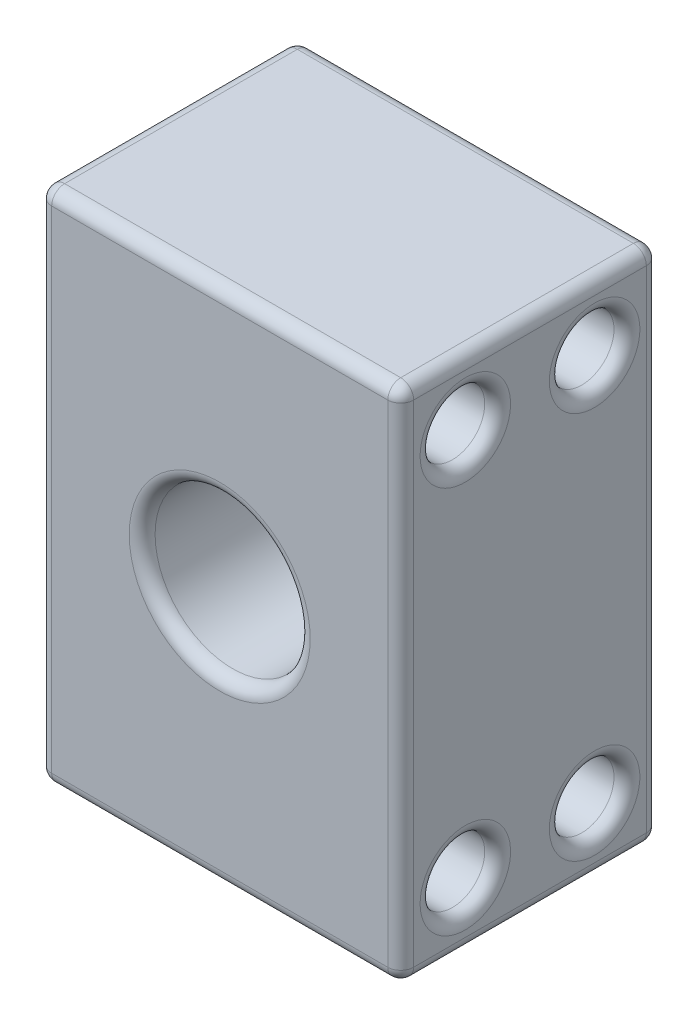
from build123d import *

# Parameters (mm, degrees)
SKETCH1_W           = 28
SKETCH1_H           = 40
BOSS_EXTRUDE1_DEPTH = 20
SKETCH2_R           = 6
CUT_EXTRUDE1_DEPTH  = 12
SKETCH3_R           = 2.5
CUT_EXTRUDE2_DEPTH  = 29
FILLET1_R           = 1


with BuildPart() as part:
    # Sketch1 → Boss-Extrude1 (new body)
    with BuildSketch(Plane.XY):
        with Locations((14, 20)):
            Rectangle(SKETCH1_W, SKETCH1_H)
    extrude(amount=BOSS_EXTRUDE1_DEPTH)

    # Sketch2 → Cut-Extrude1 (cut)
    with BuildSketch(Plane.XY.offset(20)):
        with Locations((14, 20)):
            Circle(SKETCH2_R)
    extrude(amount=-CUT_EXTRUDE1_DEPTH, mode=Mode.SUBTRACT)

    # Sketch3 → Cut-Extrude2 (cut, through all)
    with BuildSketch(Plane(origin=(28, 0, 0), x_dir=(0, 0, -1), z_dir=(1, 0, 0))):
        with Locations((-15, 35)):
            Circle(SKETCH3_R)
        with Locations((-5, 35)):
            Circle(SKETCH3_R)
        with Locations((-5, 5)):
            Circle(SKETCH3_R)
        with Locations((-15, 5)):
            Circle(SKETCH3_R)
    extrude(amount=-CUT_EXTRUDE2_DEPTH, mode=Mode.SUBTRACT)

    # Fillet1
    fillet1_edges = [part.edges().sort_by_distance(p)[0] for p in [
        (28, 20, 20),
        (8, 20, 8),
        (8, 20, 20),
        (14, 40, 20),
        (0, 5, 17.5),
        (28, 5, 17.5),
        (0, 5, 7.5),
        (28, 5, 7.5),
        (0, 35, 7.5),
        (28, 35, 7.5),
        (0, 35, 17.5),
        (28, 35, 17.5),
        (0, 20, 20),
        (14, 40, 0),
        (28, 20, 0),
        (14, 0, 0),
        (0, 20, 0),
        (0, 40, 10),
        (28, 40, 10),
        (28, 0, 10),
        (0, 0, 10),
        (14, 0, 20),
    ]]
    fillet(fillet1_edges, radius=FILLET1_R)


solid = part.part
